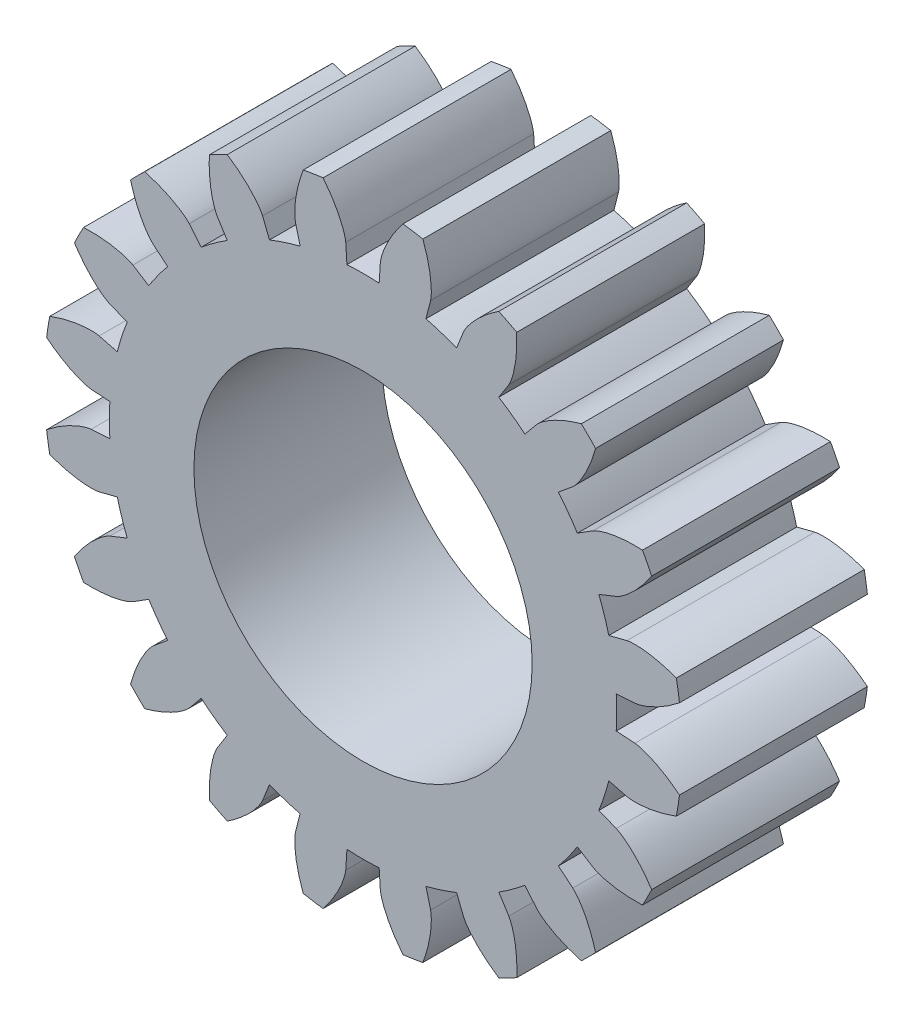
from build123d import *

# Parameters (mm, degrees)
SKETCH1_R           = 16.9725
BOSS_EXTRUDE1_DEPTH = 10
CUT_EXTRUDE1_DEPTH  = 10
CUT_EXTRUDE2_DEPTH  = 10
CIRPATTERN1_COUNT   = 20
SKETCH7_R           = 9
CUT_EXTRUDE3_DEPTH  = 10


with BuildPart() as part:
    # Sketch1 → Boss-Extrude1 (new body)
    with BuildSketch(Plane.XY):
        Circle(SKETCH1_R)
    extrude(amount=BOSS_EXTRUDE1_DEPTH)

    # Sketch3 → Cut-Extrude1 (cut)
    with BuildSketch(Plane.XY.offset(10)):
        with BuildLine():
            ThreePointArc((0.920895153, 14.467395694), (0, 14.496675), (-0.920895153, 14.467395694))
            add(Edge.make_bspline(
                [(-0.920895153, 14.467395694), (-0.931699575, 14.572901799), (-0.986226263, 14.805794679), (-1.125035007, 15.206727531), (-1.361290832, 15.711472623), (-1.907223786, 16.621543438), (-2.481610109, 17.288767267), (-2.935060111, 17.733482208)],
                knots=[0, 0, 0, 0, 0.081635878, 0.183676696, 0.326533464, 0.510206252, 1, 1, 1, 1], degree=3))
            ThreePointArc((-2.935060111, 17.733482208), (0, 17.989188903), (2.935060111, 17.733482208))
            add(Edge.make_bspline(
                [(0.920895153, 14.467395694), (0.931699575, 14.572901799), (0.986226263, 14.805794679), (1.125035007, 15.206727531), (1.361290832, 15.711472623), (1.907223786, 16.621543438), (2.481610109, 17.288767267), (2.935060111, 17.733482208)],
                knots=[0, 0, 0, 0, 0.081635878, 0.183676696, 0.326533464, 0.510206252, 1, 1, 1, 1], degree=3))
        make_face()
    cut_extrude1 = extrude(amount=-CUT_EXTRUDE1_DEPTH, mode=Mode.SUBTRACT)

    # Sketch5 → Cut-Extrude2 (cut)
    with BuildSketch(Plane.XY.offset(10)):
        with BuildLine():
            ThreePointArc((0.920895153, 14.467395694), (0, 14.496675), (-0.920895153, 14.467395694))
            Line((-0.920895153, 14.467395694), (-0.857581795, 13.472733704))
            ThreePointArc((-0.857581795, 13.472733704), (0, 13.5), (0.857581795, 13.472733704))
            Line((0.857581795, 13.472733704), (0.920895153, 14.467395694))
        make_face()
    cut_extrude2 = extrude(amount=-CUT_EXTRUDE2_DEPTH, mode=Mode.SUBTRACT)

    # CirPattern1: Cut-Extrude1, Cut-Extrude2 ×20 about axis
    cirpattern1_axis = Axis((0, 0, 10), (0, 0, -1))
    for i in range(1, CIRPATTERN1_COUNT):
        add(cut_extrude1.rotate(cirpattern1_axis, i * 360 / CIRPATTERN1_COUNT), mode=Mode.SUBTRACT)
        add(cut_extrude2.rotate(cirpattern1_axis, i * 360 / CIRPATTERN1_COUNT), mode=Mode.SUBTRACT)

    # Sketch7 → Cut-Extrude3 (cut)
    with BuildSketch(Plane.XY.offset(10)):
        Circle(SKETCH7_R)
    extrude(amount=-CUT_EXTRUDE3_DEPTH, mode=Mode.SUBTRACT)


solid = part.part
